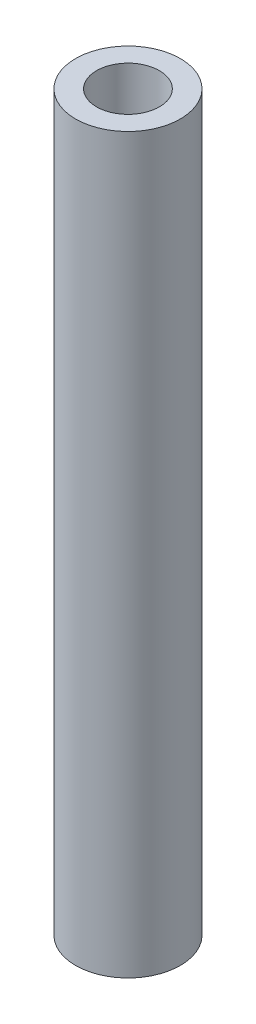
from build123d import *

# Parameters (mm, degrees)
SKETCH_1_R      = 2.5
SKETCH_1_R_2    = 1.5
EXTRUDE_1_DEPTH = 35


with BuildPart() as part:
    # 草图1 → 凸台-拉伸1 (new body)
    with BuildSketch(Plane(origin=(0, 0, 0), x_dir=(1, 0, 0), z_dir=(0, 1, 0))):
        Circle(SKETCH_1_R)
        Circle(SKETCH_1_R_2, mode=Mode.SUBTRACT)
    extrude(amount=EXTRUDE_1_DEPTH)


solid = part.part
